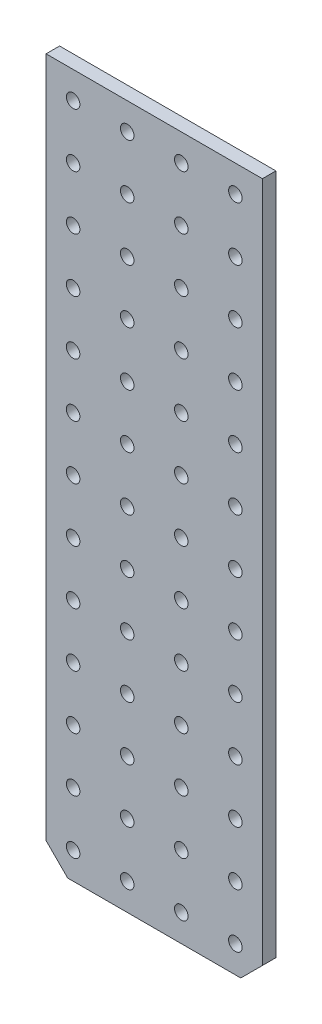
from build123d import *

# Parameters (mm, degrees)
SKETCH1_W                  = 50.8
SKETCH1_H                  = 165.1
BOSS_EXTRUDE1_DEPTH        = 3.175
SKETCH2_R                  = 1.5875
CUT_EXTRUDE1_DEPTH         = 4.175
LPATTERN1_COUNT            = 3
LPATTERN1_PITCH            = 12.7
LPATTERN1_COL_COUNT        = 2
LPATTERN1_COL_PITCH        = 12.7
LPATTERN2_COUNT            = 13
LPATTERN2_PITCH            = 12.7
LPATTERN2_COPY_1_SKETCH_R  = 1.5875
LPATTERN2_COPY_1_DEPTH     = 4.175
LPATTERN2_COPY_2_SKETCH_R  = 1.5875
LPATTERN2_COPY_2_DEPTH     = 4.175
LPATTERN2_COPY_3_SKETCH_R  = 1.5875
LPATTERN2_COPY_3_DEPTH     = 4.175
LPATTERN2_COPY_4_SKETCH_R  = 1.5875
LPATTERN2_COPY_4_DEPTH     = 4.175
LPATTERN2_COPY_5_SKETCH_R  = 1.5875
LPATTERN2_COPY_5_DEPTH     = 4.175
LPATTERN2_COPY_6_SKETCH_R  = 1.5875
LPATTERN2_COPY_6_DEPTH     = 4.175
LPATTERN2_COPY_7_SKETCH_R  = 1.5875
LPATTERN2_COPY_7_DEPTH     = 4.175
LPATTERN2_COPY_8_SKETCH_R  = 1.5875
LPATTERN2_COPY_8_DEPTH     = 4.175
LPATTERN2_COPY_9_SKETCH_R  = 1.5875
LPATTERN2_COPY_9_DEPTH     = 4.175
LPATTERN2_COPY_10_SKETCH_R = 1.5875
LPATTERN2_COPY_10_DEPTH    = 4.175
LPATTERN2_COPY_11_SKETCH_R = 1.5875
LPATTERN2_COPY_11_DEPTH    = 4.175
LPATTERN2_COPY_12_SKETCH_R = 1.5875
LPATTERN2_COPY_12_DEPTH    = 4.175
LPATTERN2_COPY_13_SKETCH_R = 1.5875
LPATTERN2_COPY_13_DEPTH    = 4.175
LPATTERN2_COPY_14_SKETCH_R = 1.5875
LPATTERN2_COPY_14_DEPTH    = 4.175
LPATTERN2_COPY_15_SKETCH_R = 1.5875
LPATTERN2_COPY_15_DEPTH    = 4.175
LPATTERN2_COPY_16_SKETCH_R = 1.5875
LPATTERN2_COPY_16_DEPTH    = 4.175
LPATTERN2_COPY_17_SKETCH_R = 1.5875
LPATTERN2_COPY_17_DEPTH    = 4.175
LPATTERN2_COPY_18_SKETCH_R = 1.5875
LPATTERN2_COPY_18_DEPTH    = 4.175
LPATTERN2_COPY_19_SKETCH_R = 1.5875
LPATTERN2_COPY_19_DEPTH    = 4.175
LPATTERN2_COPY_20_SKETCH_R = 1.5875
LPATTERN2_COPY_20_DEPTH    = 4.175
LPATTERN2_COPY_21_SKETCH_R = 1.5875
LPATTERN2_COPY_21_DEPTH    = 4.175
LPATTERN2_COPY_22_SKETCH_R = 1.5875
LPATTERN2_COPY_22_DEPTH    = 4.175
LPATTERN2_COPY_23_SKETCH_R = 1.5875
LPATTERN2_COPY_23_DEPTH    = 4.175
LPATTERN2_COPY_24_SKETCH_R = 1.5875
LPATTERN2_COPY_24_DEPTH    = 4.175
LPATTERN2_COPY_25_SKETCH_R = 1.5875
LPATTERN2_COPY_25_DEPTH    = 4.175
LPATTERN2_COPY_26_SKETCH_R = 1.5875
LPATTERN2_COPY_26_DEPTH    = 4.175
LPATTERN2_COPY_27_SKETCH_R = 1.5875
LPATTERN2_COPY_27_DEPTH    = 4.175
LPATTERN2_COPY_28_SKETCH_R = 1.5875
LPATTERN2_COPY_28_DEPTH    = 4.175
LPATTERN2_COPY_29_SKETCH_R = 1.5875
LPATTERN2_COPY_29_DEPTH    = 4.175
LPATTERN2_COPY_30_SKETCH_R = 1.5875
LPATTERN2_COPY_30_DEPTH    = 4.175
LPATTERN2_COPY_31_SKETCH_R = 1.5875
LPATTERN2_COPY_31_DEPTH    = 4.175
LPATTERN2_COPY_32_SKETCH_R = 1.5875
LPATTERN2_COPY_32_DEPTH    = 4.175
LPATTERN2_COPY_33_SKETCH_R = 1.5875
LPATTERN2_COPY_33_DEPTH    = 4.175
LPATTERN2_COPY_34_SKETCH_R = 1.5875
LPATTERN2_COPY_34_DEPTH    = 4.175
LPATTERN2_COPY_35_SKETCH_R = 1.5875
LPATTERN2_COPY_35_DEPTH    = 4.175
LPATTERN2_COPY_36_SKETCH_R = 1.5875
LPATTERN2_COPY_36_DEPTH    = 4.175
CHAMFER1_SIZE              = 5.08


with BuildPart() as part:
    # Sketch1 → Boss-Extrude1 (new body)
    with BuildSketch(Plane.XY):
        Rectangle(SKETCH1_W, SKETCH1_H)
    extrude(amount=BOSS_EXTRUDE1_DEPTH)

    # Sketch2 → Cut-Extrude1 (cut, through all)
    with BuildSketch(Plane.XY.offset(3.175)):
        with Locations((-6.35, -76.2)):
            Circle(SKETCH2_R)
    cut_extrude1 = extrude(amount=-CUT_EXTRUDE1_DEPTH, mode=Mode.SUBTRACT)

    # LPattern1: Cut-Extrude1 ×3
    with Locations(*[(i * LPATTERN1_PITCH, 0, 0) for i in range(1, LPATTERN1_COUNT)]):
        add(cut_extrude1, mode=Mode.SUBTRACT)

    # LPattern1 col: Cut-Extrude1 ×2
    with Locations(*[(-i * LPATTERN1_COL_PITCH, 0, 0) for i in range(1, LPATTERN1_COL_COUNT)]):
        add(cut_extrude1, mode=Mode.SUBTRACT)

    # LPattern2: Cut-Extrude1 ×13
    with Locations(*[(0, i * LPATTERN2_PITCH, 0) for i in range(1, LPATTERN2_COUNT)]):
        add(cut_extrude1, mode=Mode.SUBTRACT)

    # LPattern2 copy 1 sketch → LPattern2 copy 1 (cut, through all)
    with BuildSketch(Plane(origin=(12.7, 12.7, 3.175), x_dir=(1, 0, 0), z_dir=(0, 0, 1))):
        with Locations((-6.35, -76.2)):
            Circle(LPATTERN2_COPY_1_SKETCH_R)
    extrude(amount=-LPATTERN2_COPY_1_DEPTH, mode=Mode.SUBTRACT)

    # LPattern2 copy 2 sketch → LPattern2 copy 2 (cut, through all)
    with BuildSketch(Plane(origin=(12.7, 25.4, 3.175), x_dir=(1, 0, 0), z_dir=(0, 0, 1))):
        with Locations((-6.35, -76.2)):
            Circle(LPATTERN2_COPY_2_SKETCH_R)
    extrude(amount=-LPATTERN2_COPY_2_DEPTH, mode=Mode.SUBTRACT)

    # LPattern2 copy 3 sketch → LPattern2 copy 3 (cut, through all)
    with BuildSketch(Plane(origin=(12.7, 38.1, 3.175), x_dir=(1, 0, 0), z_dir=(0, 0, 1))):
        with Locations((-6.35, -76.2)):
            Circle(LPATTERN2_COPY_3_SKETCH_R)
    extrude(amount=-LPATTERN2_COPY_3_DEPTH, mode=Mode.SUBTRACT)

    # LPattern2 copy 4 sketch → LPattern2 copy 4 (cut, through all)
    with BuildSketch(Plane(origin=(12.7, 50.8, 3.175), x_dir=(1, 0, 0), z_dir=(0, 0, 1))):
        with Locations((-6.35, -76.2)):
            Circle(LPATTERN2_COPY_4_SKETCH_R)
    extrude(amount=-LPATTERN2_COPY_4_DEPTH, mode=Mode.SUBTRACT)

    # LPattern2 copy 5 sketch → LPattern2 copy 5 (cut, through all)
    with BuildSketch(Plane(origin=(12.7, 63.5, 3.175), x_dir=(1, 0, 0), z_dir=(0, 0, 1))):
        with Locations((-6.35, -76.2)):
            Circle(LPATTERN2_COPY_5_SKETCH_R)
    extrude(amount=-LPATTERN2_COPY_5_DEPTH, mode=Mode.SUBTRACT)

    # LPattern2 copy 6 sketch → LPattern2 copy 6 (cut, through all)
    with BuildSketch(Plane(origin=(12.7, 76.2, 3.175), x_dir=(1, 0, 0), z_dir=(0, 0, 1))):
        with Locations((-6.35, -76.2)):
            Circle(LPATTERN2_COPY_6_SKETCH_R)
    extrude(amount=-LPATTERN2_COPY_6_DEPTH, mode=Mode.SUBTRACT)

    # LPattern2 copy 7 sketch → LPattern2 copy 7 (cut, through all)
    with BuildSketch(Plane(origin=(12.7, 88.9, 3.175), x_dir=(1, 0, 0), z_dir=(0, 0, 1))):
        with Locations((-6.35, -76.2)):
            Circle(LPATTERN2_COPY_7_SKETCH_R)
    extrude(amount=-LPATTERN2_COPY_7_DEPTH, mode=Mode.SUBTRACT)

    # LPattern2 copy 8 sketch → LPattern2 copy 8 (cut, through all)
    with BuildSketch(Plane(origin=(12.7, 101.6, 3.175), x_dir=(1, 0, 0), z_dir=(0, 0, 1))):
        with Locations((-6.35, -76.2)):
            Circle(LPATTERN2_COPY_8_SKETCH_R)
    extrude(amount=-LPATTERN2_COPY_8_DEPTH, mode=Mode.SUBTRACT)

    # LPattern2 copy 9 sketch → LPattern2 copy 9 (cut, through all)
    with BuildSketch(Plane(origin=(12.7, 114.3, 3.175), x_dir=(1, 0, 0), z_dir=(0, 0, 1))):
        with Locations((-6.35, -76.2)):
            Circle(LPATTERN2_COPY_9_SKETCH_R)
    extrude(amount=-LPATTERN2_COPY_9_DEPTH, mode=Mode.SUBTRACT)

    # LPattern2 copy 10 sketch → LPattern2 copy 10 (cut, through all)
    with BuildSketch(Plane(origin=(12.7, 127, 3.175), x_dir=(1, 0, 0), z_dir=(0, 0, 1))):
        with Locations((-6.35, -76.2)):
            Circle(LPATTERN2_COPY_10_SKETCH_R)
    extrude(amount=-LPATTERN2_COPY_10_DEPTH, mode=Mode.SUBTRACT)

    # LPattern2 copy 11 sketch → LPattern2 copy 11 (cut, through all)
    with BuildSketch(Plane(origin=(12.7, 139.7, 3.175), x_dir=(1, 0, 0), z_dir=(0, 0, 1))):
        with Locations((-6.35, -76.2)):
            Circle(LPATTERN2_COPY_11_SKETCH_R)
    extrude(amount=-LPATTERN2_COPY_11_DEPTH, mode=Mode.SUBTRACT)

    # LPattern2 copy 12 sketch → LPattern2 copy 12 (cut, through all)
    with BuildSketch(Plane(origin=(12.7, 152.4, 3.175), x_dir=(1, 0, 0), z_dir=(0, 0, 1))):
        with Locations((-6.35, -76.2)):
            Circle(LPATTERN2_COPY_12_SKETCH_R)
    extrude(amount=-LPATTERN2_COPY_12_DEPTH, mode=Mode.SUBTRACT)

    # LPattern2 copy 13 sketch → LPattern2 copy 13 (cut, through all)
    with BuildSketch(Plane(origin=(25.4, 12.7, 3.175), x_dir=(1, 0, 0), z_dir=(0, 0, 1))):
        with Locations((-6.35, -76.2)):
            Circle(LPATTERN2_COPY_13_SKETCH_R)
    extrude(amount=-LPATTERN2_COPY_13_DEPTH, mode=Mode.SUBTRACT)

    # LPattern2 copy 14 sketch → LPattern2 copy 14 (cut, through all)
    with BuildSketch(Plane(origin=(25.4, 25.4, 3.175), x_dir=(1, 0, 0), z_dir=(0, 0, 1))):
        with Locations((-6.35, -76.2)):
            Circle(LPATTERN2_COPY_14_SKETCH_R)
    extrude(amount=-LPATTERN2_COPY_14_DEPTH, mode=Mode.SUBTRACT)

    # LPattern2 copy 15 sketch → LPattern2 copy 15 (cut, through all)
    with BuildSketch(Plane(origin=(25.4, 38.1, 3.175), x_dir=(1, 0, 0), z_dir=(0, 0, 1))):
        with Locations((-6.35, -76.2)):
            Circle(LPATTERN2_COPY_15_SKETCH_R)
    extrude(amount=-LPATTERN2_COPY_15_DEPTH, mode=Mode.SUBTRACT)

    # LPattern2 copy 16 sketch → LPattern2 copy 16 (cut, through all)
    with BuildSketch(Plane(origin=(25.4, 50.8, 3.175), x_dir=(1, 0, 0), z_dir=(0, 0, 1))):
        with Locations((-6.35, -76.2)):
            Circle(LPATTERN2_COPY_16_SKETCH_R)
    extrude(amount=-LPATTERN2_COPY_16_DEPTH, mode=Mode.SUBTRACT)

    # LPattern2 copy 17 sketch → LPattern2 copy 17 (cut, through all)
    with BuildSketch(Plane(origin=(25.4, 63.5, 3.175), x_dir=(1, 0, 0), z_dir=(0, 0, 1))):
        with Locations((-6.35, -76.2)):
            Circle(LPATTERN2_COPY_17_SKETCH_R)
    extrude(amount=-LPATTERN2_COPY_17_DEPTH, mode=Mode.SUBTRACT)

    # LPattern2 copy 18 sketch → LPattern2 copy 18 (cut, through all)
    with BuildSketch(Plane(origin=(25.4, 76.2, 3.175), x_dir=(1, 0, 0), z_dir=(0, 0, 1))):
        with Locations((-6.35, -76.2)):
            Circle(LPATTERN2_COPY_18_SKETCH_R)
    extrude(amount=-LPATTERN2_COPY_18_DEPTH, mode=Mode.SUBTRACT)

    # LPattern2 copy 19 sketch → LPattern2 copy 19 (cut, through all)
    with BuildSketch(Plane(origin=(25.4, 88.9, 3.175), x_dir=(1, 0, 0), z_dir=(0, 0, 1))):
        with Locations((-6.35, -76.2)):
            Circle(LPATTERN2_COPY_19_SKETCH_R)
    extrude(amount=-LPATTERN2_COPY_19_DEPTH, mode=Mode.SUBTRACT)

    # LPattern2 copy 20 sketch → LPattern2 copy 20 (cut, through all)
    with BuildSketch(Plane(origin=(25.4, 101.6, 3.175), x_dir=(1, 0, 0), z_dir=(0, 0, 1))):
        with Locations((-6.35, -76.2)):
            Circle(LPATTERN2_COPY_20_SKETCH_R)
    extrude(amount=-LPATTERN2_COPY_20_DEPTH, mode=Mode.SUBTRACT)

    # LPattern2 copy 21 sketch → LPattern2 copy 21 (cut, through all)
    with BuildSketch(Plane(origin=(25.4, 114.3, 3.175), x_dir=(1, 0, 0), z_dir=(0, 0, 1))):
        with Locations((-6.35, -76.2)):
            Circle(LPATTERN2_COPY_21_SKETCH_R)
    extrude(amount=-LPATTERN2_COPY_21_DEPTH, mode=Mode.SUBTRACT)

    # LPattern2 copy 22 sketch → LPattern2 copy 22 (cut, through all)
    with BuildSketch(Plane(origin=(25.4, 127, 3.175), x_dir=(1, 0, 0), z_dir=(0, 0, 1))):
        with Locations((-6.35, -76.2)):
            Circle(LPATTERN2_COPY_22_SKETCH_R)
    extrude(amount=-LPATTERN2_COPY_22_DEPTH, mode=Mode.SUBTRACT)

    # LPattern2 copy 23 sketch → LPattern2 copy 23 (cut, through all)
    with BuildSketch(Plane(origin=(25.4, 139.7, 3.175), x_dir=(1, 0, 0), z_dir=(0, 0, 1))):
        with Locations((-6.35, -76.2)):
            Circle(LPATTERN2_COPY_23_SKETCH_R)
    extrude(amount=-LPATTERN2_COPY_23_DEPTH, mode=Mode.SUBTRACT)

    # LPattern2 copy 24 sketch → LPattern2 copy 24 (cut, through all)
    with BuildSketch(Plane(origin=(25.4, 152.4, 3.175), x_dir=(1, 0, 0), z_dir=(0, 0, 1))):
        with Locations((-6.35, -76.2)):
            Circle(LPATTERN2_COPY_24_SKETCH_R)
    extrude(amount=-LPATTERN2_COPY_24_DEPTH, mode=Mode.SUBTRACT)

    # LPattern2 copy 25 sketch → LPattern2 copy 25 (cut, through all)
    with BuildSketch(Plane(origin=(-12.7, 12.7, 3.175), x_dir=(1, 0, 0), z_dir=(0, 0, 1))):
        with Locations((-6.35, -76.2)):
            Circle(LPATTERN2_COPY_25_SKETCH_R)
    extrude(amount=-LPATTERN2_COPY_25_DEPTH, mode=Mode.SUBTRACT)

    # LPattern2 copy 26 sketch → LPattern2 copy 26 (cut, through all)
    with BuildSketch(Plane(origin=(-12.7, 25.4, 3.175), x_dir=(1, 0, 0), z_dir=(0, 0, 1))):
        with Locations((-6.35, -76.2)):
            Circle(LPATTERN2_COPY_26_SKETCH_R)
    extrude(amount=-LPATTERN2_COPY_26_DEPTH, mode=Mode.SUBTRACT)

    # LPattern2 copy 27 sketch → LPattern2 copy 27 (cut, through all)
    with BuildSketch(Plane(origin=(-12.7, 38.1, 3.175), x_dir=(1, 0, 0), z_dir=(0, 0, 1))):
        with Locations((-6.35, -76.2)):
            Circle(LPATTERN2_COPY_27_SKETCH_R)
    extrude(amount=-LPATTERN2_COPY_27_DEPTH, mode=Mode.SUBTRACT)

    # LPattern2 copy 28 sketch → LPattern2 copy 28 (cut, through all)
    with BuildSketch(Plane(origin=(-12.7, 50.8, 3.175), x_dir=(1, 0, 0), z_dir=(0, 0, 1))):
        with Locations((-6.35, -76.2)):
            Circle(LPATTERN2_COPY_28_SKETCH_R)
    extrude(amount=-LPATTERN2_COPY_28_DEPTH, mode=Mode.SUBTRACT)

    # LPattern2 copy 29 sketch → LPattern2 copy 29 (cut, through all)
    with BuildSketch(Plane(origin=(-12.7, 63.5, 3.175), x_dir=(1, 0, 0), z_dir=(0, 0, 1))):
        with Locations((-6.35, -76.2)):
            Circle(LPATTERN2_COPY_29_SKETCH_R)
    extrude(amount=-LPATTERN2_COPY_29_DEPTH, mode=Mode.SUBTRACT)

    # LPattern2 copy 30 sketch → LPattern2 copy 30 (cut, through all)
    with BuildSketch(Plane(origin=(-12.7, 76.2, 3.175), x_dir=(1, 0, 0), z_dir=(0, 0, 1))):
        with Locations((-6.35, -76.2)):
            Circle(LPATTERN2_COPY_30_SKETCH_R)
    extrude(amount=-LPATTERN2_COPY_30_DEPTH, mode=Mode.SUBTRACT)

    # LPattern2 copy 31 sketch → LPattern2 copy 31 (cut, through all)
    with BuildSketch(Plane(origin=(-12.7, 88.9, 3.175), x_dir=(1, 0, 0), z_dir=(0, 0, 1))):
        with Locations((-6.35, -76.2)):
            Circle(LPATTERN2_COPY_31_SKETCH_R)
    extrude(amount=-LPATTERN2_COPY_31_DEPTH, mode=Mode.SUBTRACT)

    # LPattern2 copy 32 sketch → LPattern2 copy 32 (cut, through all)
    with BuildSketch(Plane(origin=(-12.7, 101.6, 3.175), x_dir=(1, 0, 0), z_dir=(0, 0, 1))):
        with Locations((-6.35, -76.2)):
            Circle(LPATTERN2_COPY_32_SKETCH_R)
    extrude(amount=-LPATTERN2_COPY_32_DEPTH, mode=Mode.SUBTRACT)

    # LPattern2 copy 33 sketch → LPattern2 copy 33 (cut, through all)
    with BuildSketch(Plane(origin=(-12.7, 114.3, 3.175), x_dir=(1, 0, 0), z_dir=(0, 0, 1))):
        with Locations((-6.35, -76.2)):
            Circle(LPATTERN2_COPY_33_SKETCH_R)
    extrude(amount=-LPATTERN2_COPY_33_DEPTH, mode=Mode.SUBTRACT)

    # LPattern2 copy 34 sketch → LPattern2 copy 34 (cut, through all)
    with BuildSketch(Plane(origin=(-12.7, 127, 3.175), x_dir=(1, 0, 0), z_dir=(0, 0, 1))):
        with Locations((-6.35, -76.2)):
            Circle(LPATTERN2_COPY_34_SKETCH_R)
    extrude(amount=-LPATTERN2_COPY_34_DEPTH, mode=Mode.SUBTRACT)

    # LPattern2 copy 35 sketch → LPattern2 copy 35 (cut, through all)
    with BuildSketch(Plane(origin=(-12.7, 139.7, 3.175), x_dir=(1, 0, 0), z_dir=(0, 0, 1))):
        with Locations((-6.35, -76.2)):
            Circle(LPATTERN2_COPY_35_SKETCH_R)
    extrude(amount=-LPATTERN2_COPY_35_DEPTH, mode=Mode.SUBTRACT)

    # LPattern2 copy 36 sketch → LPattern2 copy 36 (cut, through all)
    with BuildSketch(Plane(origin=(-12.7, 152.4, 3.175), x_dir=(1, 0, 0), z_dir=(0, 0, 1))):
        with Locations((-6.35, -76.2)):
            Circle(LPATTERN2_COPY_36_SKETCH_R)
    extrude(amount=-LPATTERN2_COPY_36_DEPTH, mode=Mode.SUBTRACT)

    # Chamfer1
    chamfer1_edges = [part.edges().sort_by_distance(p)[0] for p in [
        (25.4, -82.55, 1.5875),
        (-25.4, -82.55, 1.5875),
    ]]
    chamfer(chamfer1_edges, length=CHAMFER1_SIZE)


solid = part.part
